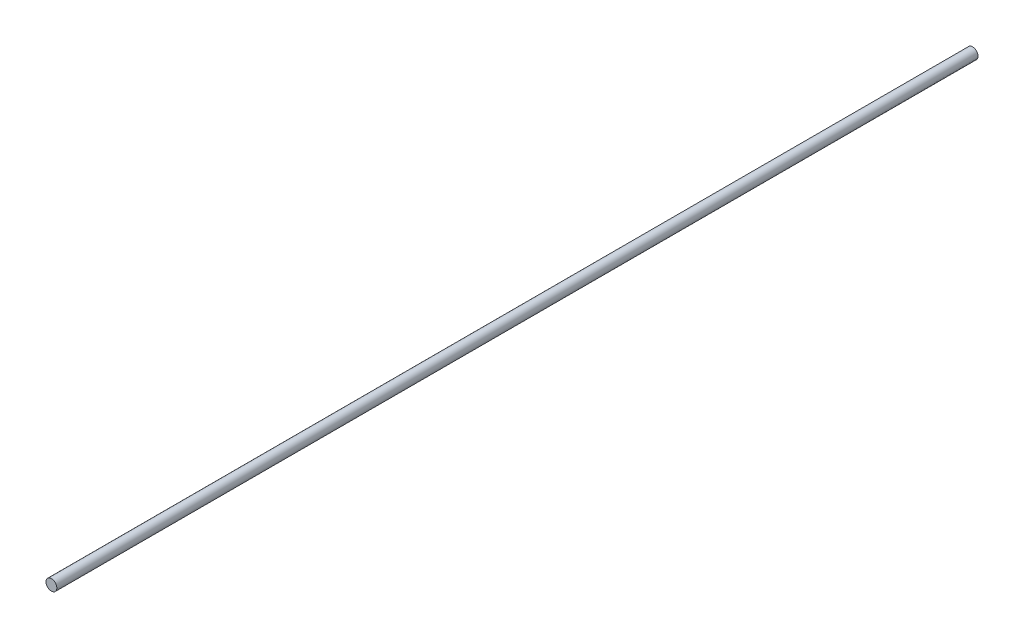
from build123d import *

# Parameters (mm, degrees)
ESQUISSE1_R        = 4
BOSS_EXTRU_1_DEPTH = 680


with BuildPart() as part:
    # Esquisse1 → Boss.-Extru.1 (new body)
    with BuildSketch(Plane.XY):
        Circle(ESQUISSE1_R)
    extrude(amount=BOSS_EXTRU_1_DEPTH)


solid = part.part
